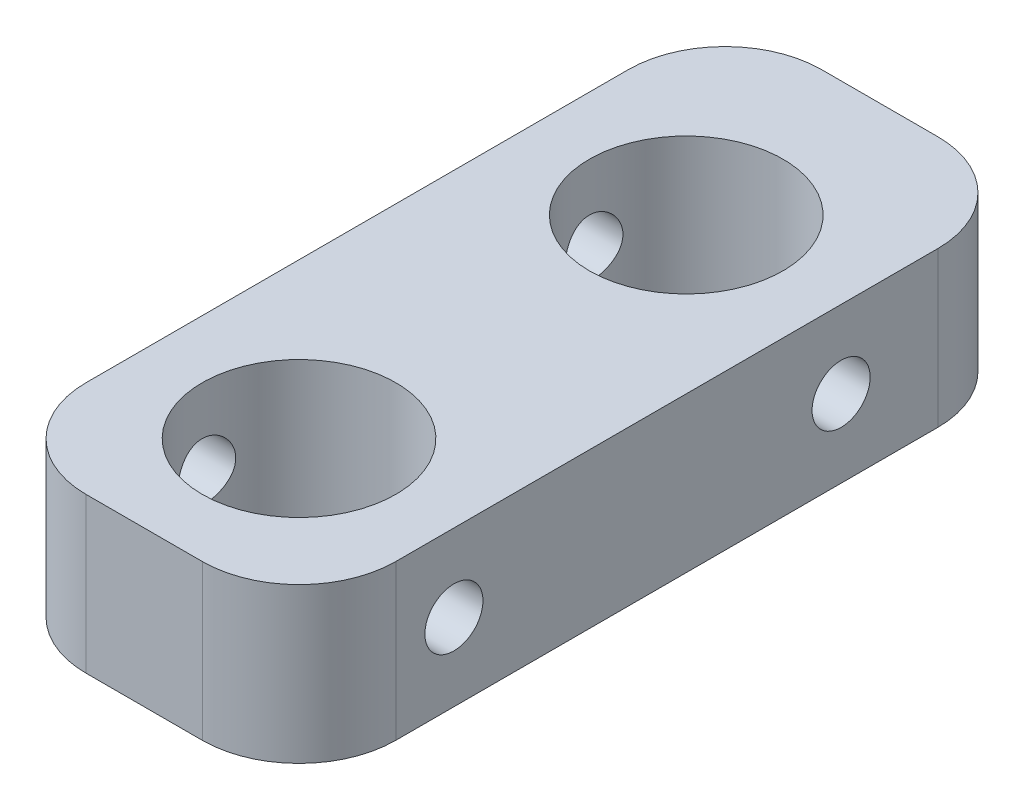
from build123d import *

# Parameters (mm, degrees)
SKETCH1_R           = 5
BOSS_EXTRUDE1_DEPTH = 8
SKETCH2_R           = 1.5
CUT_EXTRUDE1_DEPTH  = 17


with BuildPart() as part:
    # Sketch1 → Boss-Extrude1 (new body)
    with BuildSketch(Plane(origin=(0, 0, 0), x_dir=(1, 0, 0), z_dir=(0, 1, 0))):
        with BuildLine():
            Line((-2.673601855, -35.379310345), (3.326398145, -35.379310345))
            ThreePointArc((3.326398145, -35.379310345), (6.861932051, -33.914844251), (8.326398145, -30.379310345))
            Line((8.326398145, -30.379310345), (8.326398145, -2.379310345))
            ThreePointArc((8.326398145, -2.379310345), (6.861932051, 1.156223561), (3.326398145, 2.620689655))
            Line((3.326398145, 2.620689655), (-2.673601855, 2.620689655))
            ThreePointArc((-2.673601855, 2.620689655), (-6.20913576, 1.156223561), (-7.673601855, -2.379310345))
            Line((-7.673601855, -2.379310345), (-7.673601855, -30.379310345))
            ThreePointArc((-7.673601855, -30.379310345), (-6.20913576, -33.914844251), (-2.673601855, -35.379310345))
        make_face()
        with Locations((0.326398145, -27.379310345)):
            Circle(SKETCH1_R, mode=Mode.SUBTRACT)
        with Locations((0.326398145, -7.379310345)):
            Circle(SKETCH1_R, mode=Mode.SUBTRACT)
    extrude(amount=BOSS_EXTRUDE1_DEPTH)

    # Sketch2 → Cut-Extrude1 (cut, through all)
    with BuildSketch(Plane(origin=(8.326398145, 0, 0), x_dir=(0, 0, -1), z_dir=(1, 0, 0))):
        with Locations((-27.379310345, 4)):
            Circle(SKETCH2_R)
        with Locations((-7.379310345, 4)):
            Circle(SKETCH2_R)
    extrude(amount=-CUT_EXTRUDE1_DEPTH, mode=Mode.SUBTRACT)


solid = part.part
